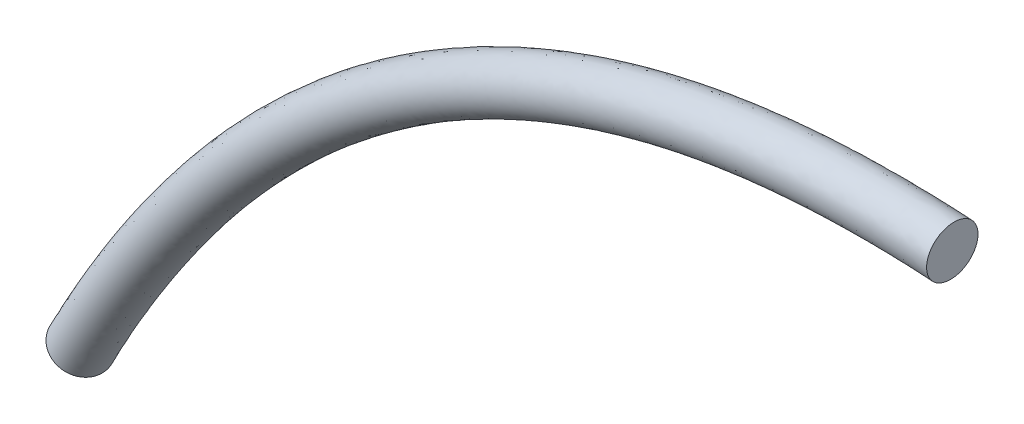
from build123d import *

# Parameters (mm, degrees)
SWEEP1_PROFILE_R = 4.699


with BuildPart() as part:
    # Sweep1: sweep along a curve in space
    with BuildLine() as sweep1_path:
        add(Edge.make_bspline(
            [(-244.225633911, -166.510690166, 163.32176145), (-172.691022825, -46.863058052, 181.81588183), (-66.61351475, -53.682436204, 181.6608)],
            knots=[0, 0, 0, 1, 1, 1], degree=2))
    # Sweep1 profile (on start of the path) → Sweep1 (sweep)
    with BuildSketch(Plane(origin=(-244.225633911, -166.510690166, 163.32176145), x_dir=(0.858295636, -0.513155534, 0), z_dir=(0.508698307, 0.85084055, 0.131515746))):
        Circle(SWEEP1_PROFILE_R)
    sweep(path=sweep1_path.line)


solid = part.part
